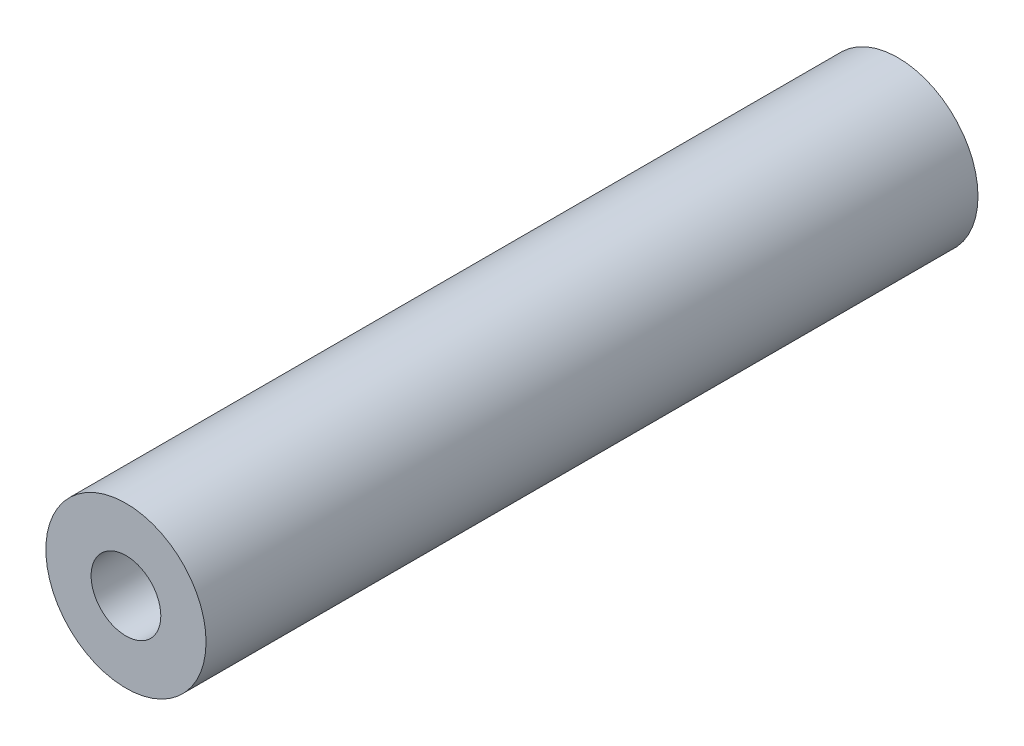
from build123d import *

# Parameters (mm, degrees)
SKETCH1_R           = 13.49
SKETCH1_R_2         = 5.87
BOSS_EXTRUDE1_DEPTH = 130


with BuildPart() as part:
    # Sketch1 → Boss-Extrude1 (new body)
    with BuildSketch(Plane.XY):
        Circle(SKETCH1_R)
        Circle(SKETCH1_R_2, mode=Mode.SUBTRACT)
    extrude(amount=BOSS_EXTRUDE1_DEPTH)


solid = part.part
